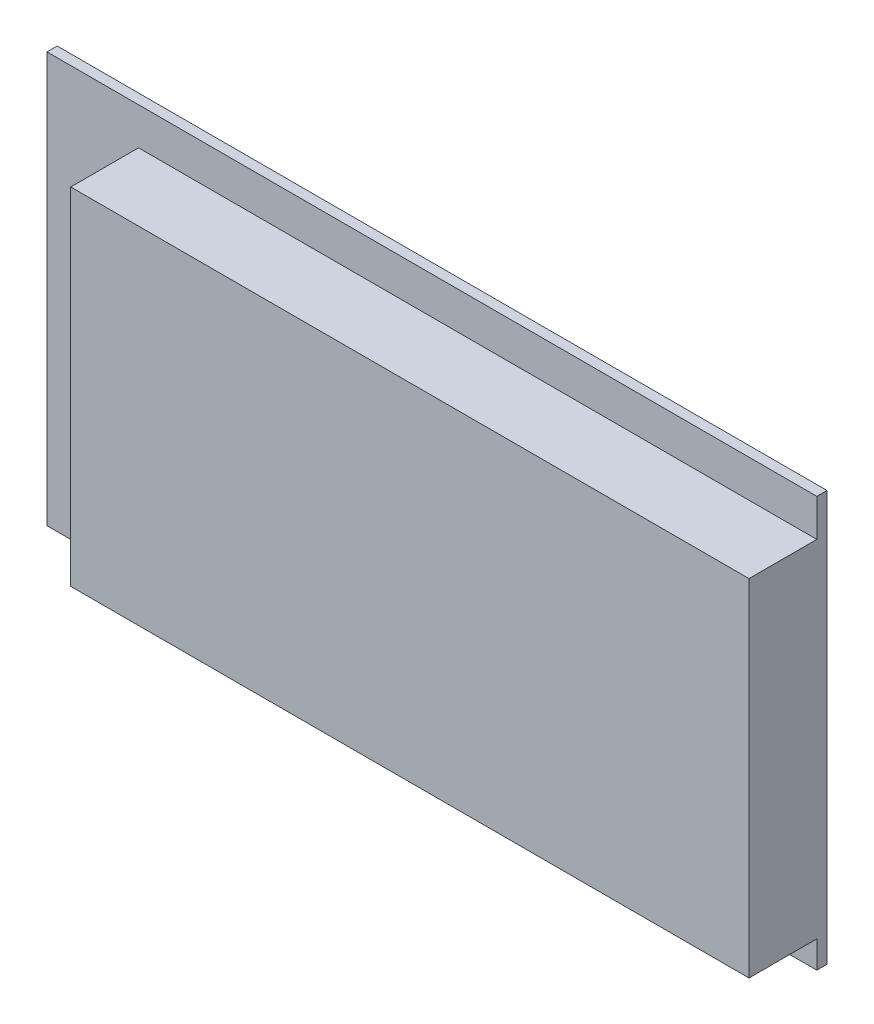
from build123d import *

# Parameters (mm, degrees)
ESQUISSE1_W        = 113.5
ESQUISSE1_H        = 60.5
BOSS_EXTRU_1_DEPTH = 1.5
ESQUISSE2_W        = 100
ESQUISSE2_H        = 51
BOSS_EXTRU_2_DEPTH = 10


with BuildPart() as part:
    # Esquisse1 → Boss.-Extru.1 (new body)
    with BuildSketch(Plane.XY):
        with Locations((56.75, 30.25)):
            Rectangle(ESQUISSE1_W, ESQUISSE1_H)
    extrude(amount=BOSS_EXTRU_1_DEPTH)

    # Esquisse2 → Boss.-Extru.2 (add)
    with BuildSketch(Plane.XY.offset(1.5)):
        with Locations((63.5, 29.5)):
            Rectangle(ESQUISSE2_W, ESQUISSE2_H)
    extrude(amount=BOSS_EXTRU_2_DEPTH)


solid = part.part
